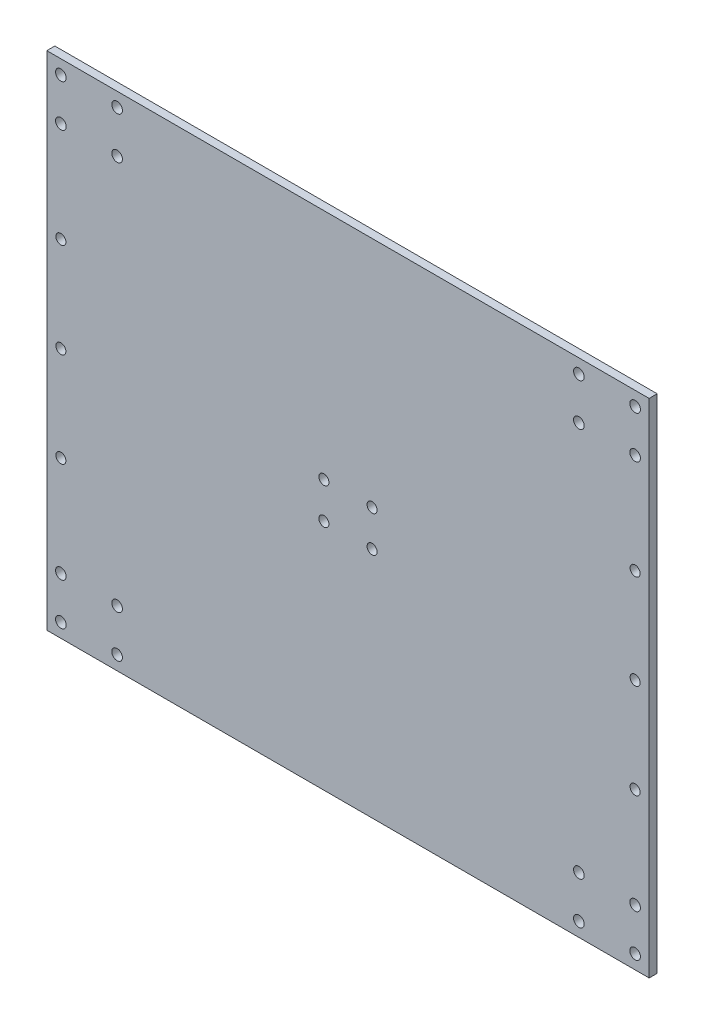
from build123d import *

# Parameters (mm, degrees)
SKETCH2_W           = 300
SKETCH2_H           = 250
SKETCH2_R           = 2.649999999
SKETCH2_R_2         = 2.65
SKETCH2_R_3         = 2.5
BOSS_EXTRUDE1_DEPTH = 4


with BuildPart() as part:
    # Sketch2 (on Front Plane) → Boss-Extrude1 (new body)
    with BuildSketch(Plane.XY):
        with Locations((150, 125)):
            Rectangle(SKETCH2_W, SKETCH2_H)
        with Locations((293.000000001, 243)):
            Circle(SKETCH2_R, mode=Mode.SUBTRACT)
        with Locations((265.000000001, 243)):
            Circle(SKETCH2_R, mode=Mode.SUBTRACT)
        with Locations((265.000000001, 222)):
            Circle(SKETCH2_R, mode=Mode.SUBTRACT)
        with Locations((293.000000001, 222)):
            Circle(SKETCH2_R, mode=Mode.SUBTRACT)
        with Locations((35, 243)):
            Circle(SKETCH2_R_2, mode=Mode.SUBTRACT)
        with Locations((7, 243)):
            Circle(SKETCH2_R_2, mode=Mode.SUBTRACT)
        with Locations((7, 222)):
            Circle(SKETCH2_R_2, mode=Mode.SUBTRACT)
        with Locations((35, 222)):
            Circle(SKETCH2_R_2, mode=Mode.SUBTRACT)
        with Locations((7, 28)):
            Circle(SKETCH2_R_2, mode=Mode.SUBTRACT)
        with Locations((7, 7)):
            Circle(SKETCH2_R_2, mode=Mode.SUBTRACT)
        with Locations((35, 7)):
            Circle(SKETCH2_R_2, mode=Mode.SUBTRACT)
        with Locations((35, 28)):
            Circle(SKETCH2_R_2, mode=Mode.SUBTRACT)
        with Locations((265, 28)):
            Circle(SKETCH2_R_2, mode=Mode.SUBTRACT)
        with Locations((265, 7)):
            Circle(SKETCH2_R_2, mode=Mode.SUBTRACT)
        with Locations((293, 7)):
            Circle(SKETCH2_R_2, mode=Mode.SUBTRACT)
        with Locations((293, 28)):
            Circle(SKETCH2_R_2, mode=Mode.SUBTRACT)
        with Locations((162, 134)):
            Circle(SKETCH2_R_3, mode=Mode.SUBTRACT)
        with Locations((138, 134)):
            Circle(SKETCH2_R_3, mode=Mode.SUBTRACT)
        with Locations((138, 116)):
            Circle(SKETCH2_R_3, mode=Mode.SUBTRACT)
        with Locations((162, 116)):
            Circle(SKETCH2_R_3, mode=Mode.SUBTRACT)
        with Locations((7, 125)):
            Circle(SKETCH2_R_3, mode=Mode.SUBTRACT)
        with Locations((7, 77.825)):
            Circle(SKETCH2_R_3, mode=Mode.SUBTRACT)
        with Locations((7, 172.175)):
            Circle(SKETCH2_R_3, mode=Mode.SUBTRACT)
        with Locations((293, 125)):
            Circle(SKETCH2_R_3, mode=Mode.SUBTRACT)
        with Locations((293, 77.825)):
            Circle(SKETCH2_R_3, mode=Mode.SUBTRACT)
        with Locations((293, 172.175)):
            Circle(SKETCH2_R_3, mode=Mode.SUBTRACT)
    extrude(amount=BOSS_EXTRUDE1_DEPTH)


solid = part.part
